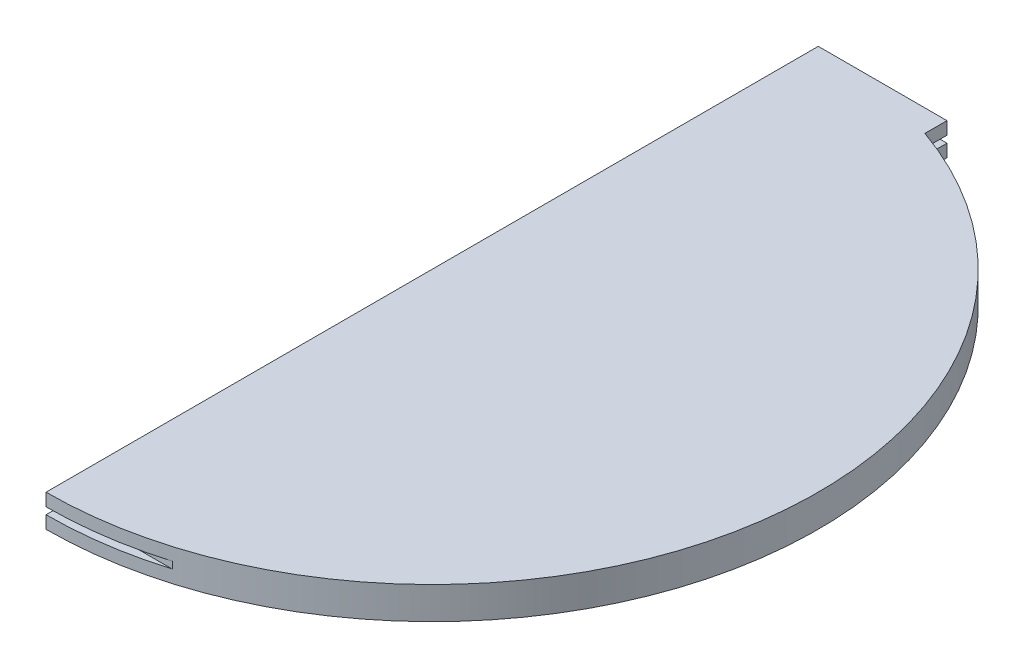
from build123d import *

# Parameters (mm, degrees)
BOSS_EXTRUDE1_DEPTH = 38.1
SKETCH2_W           = 38.1
SKETCH2_H           = 8.128
CUT_EXTRUDE1_DEPTH  = 458.2


with BuildPart() as part:
    # Sketch1 → Boss-Extrude1 (new body)
    with BuildSketch(Plane(origin=(0, 0, 0), x_dir=(1, 0, 0), z_dir=(0, 1, 0))):
        with BuildLine():
            Line((-228.6, 457.2), (-76.2, 457.2))
            Line((-76.2, 457.2), (-76.2, 431.052293811))
            ThreePointArc((-76.2, 431.052293811), (222.015661474, -77.313424673), (-228.6, -457.2))
            Line((-228.6, -457.2), (-228.6, 457.2))
        make_face()
    extrude(amount=BOSS_EXTRUDE1_DEPTH)

    # Sketch2 → Cut-Extrude1 (cut, through all)
    with BuildSketch(Plane.ZY.offset(228.6)):
        with Locations((457.2, 19.05)):
            Rectangle(SKETCH2_W, SKETCH2_H)
        with Locations((-457.2, 19.05)):
            Rectangle(SKETCH2_W, SKETCH2_H)
    extrude(amount=-CUT_EXTRUDE1_DEPTH, mode=Mode.SUBTRACT)


solid = part.part
